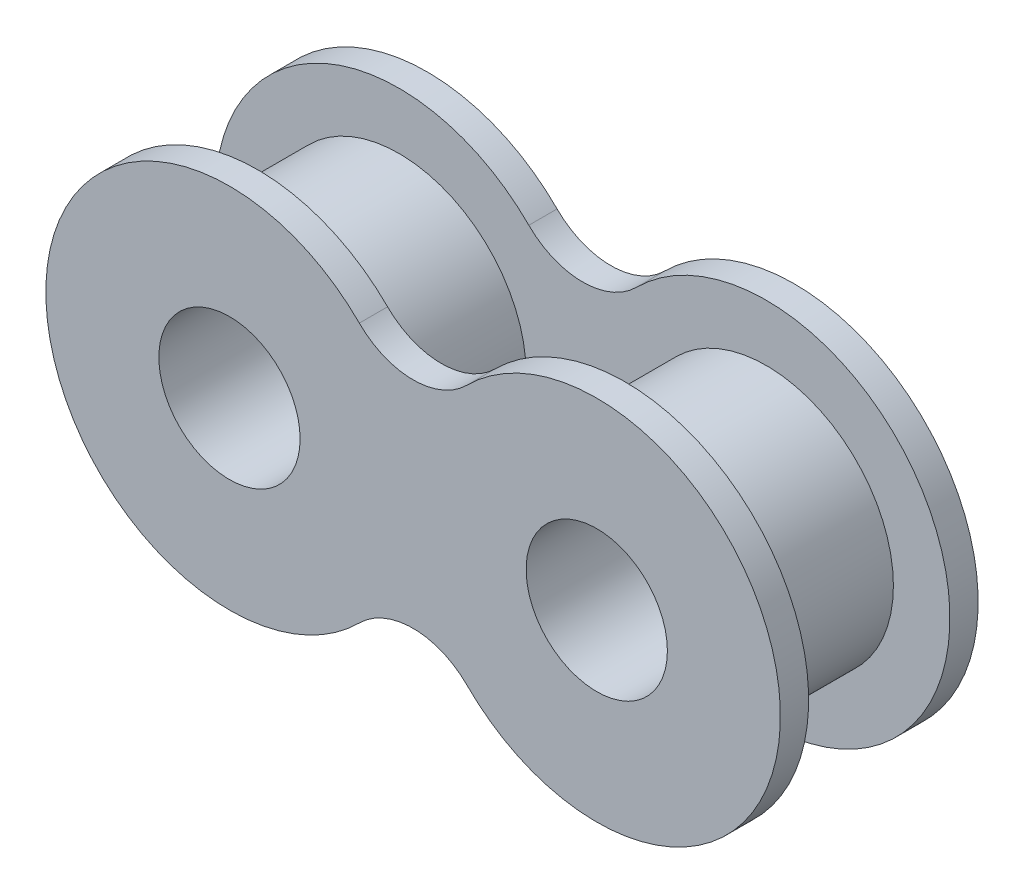
from build123d import *

# Parameters (mm, degrees)
CROQUIS1_R              = 2.5
SALIENTE_EXTRUIR1_DEPTH = 1
CROQUIS2_R              = 4.5
CROQUIS2_R_2            = 2.5
SALIENTE_EXTRUIR2_DEPTH = 5


with BuildPart() as part:
    # Croquis1 → Saliente-Extruir1 (new body)
    with BuildSketch(Plane.XY):
        with BuildLine():
            ThreePointArc((-1.903805922, 4.596194078), (-13, 0), (-1.903805922, -4.596194078))
            ThreePointArc((-1.903805922, -4.596194078), (0, -3.807611845), (1.903805922, -4.596194078))
            ThreePointArc((1.903805922, -4.596194078), (13, 0), (1.903805922, 4.596194078))
            ThreePointArc((1.903805922, 4.596194078), (0, 3.807611845), (-1.903805922, 4.596194078))
        make_face()
        with Locations((-6.5, 0)):
            Circle(CROQUIS1_R, mode=Mode.SUBTRACT)
        with Locations((6.5, 0)):
            Circle(CROQUIS1_R, mode=Mode.SUBTRACT)
    saliente_extruir1 = extrude(amount=SALIENTE_EXTRUIR1_DEPTH)

    # Croquis2 → Saliente-Extruir2 (add)
    with BuildSketch(Plane.XY.offset(1)):
        with Locations((6.5, 0)):
            Circle(CROQUIS2_R)
        with Locations((6.5, 0)):
            Circle(CROQUIS2_R_2, mode=Mode.SUBTRACT)
        with Locations((-6.5, 0)):
            Circle(CROQUIS2_R)
        with Locations((-6.5, 0)):
            Circle(CROQUIS2_R_2, mode=Mode.SUBTRACT)
    extrude(amount=SALIENTE_EXTRUIR2_DEPTH)

    # Simetría1: Saliente-Extruir1 across plane
    add(saliente_extruir1.mirror(Plane.XY.offset(3.5)))


solid = part.part
